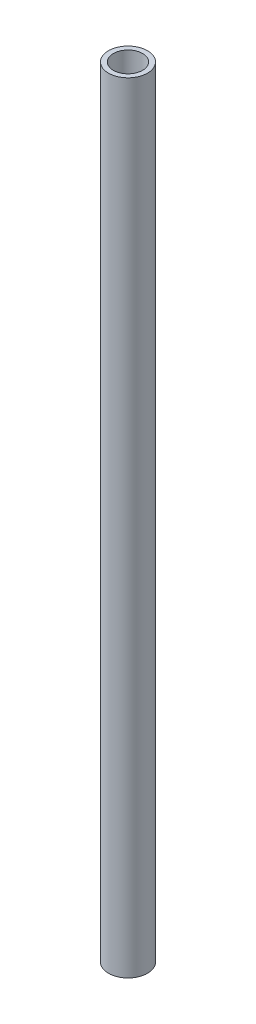
from build123d import *

# Parameters (mm, degrees)
SKETCH1_R           = 2
SKETCH1_R_2         = 1.5
BOSS_EXTRUDE1_DEPTH = 40


with BuildPart() as part:
    # Sketch1 → Boss-Extrude1 (new body, symmetric)
    with BuildSketch(Plane(origin=(0, 0, 0), x_dir=(1, 0, 0), z_dir=(0, 1, 0))):
        Circle(SKETCH1_R)
        Circle(SKETCH1_R_2, mode=Mode.SUBTRACT)
    extrude(amount=BOSS_EXTRUDE1_DEPTH, both=True)


solid = part.part
